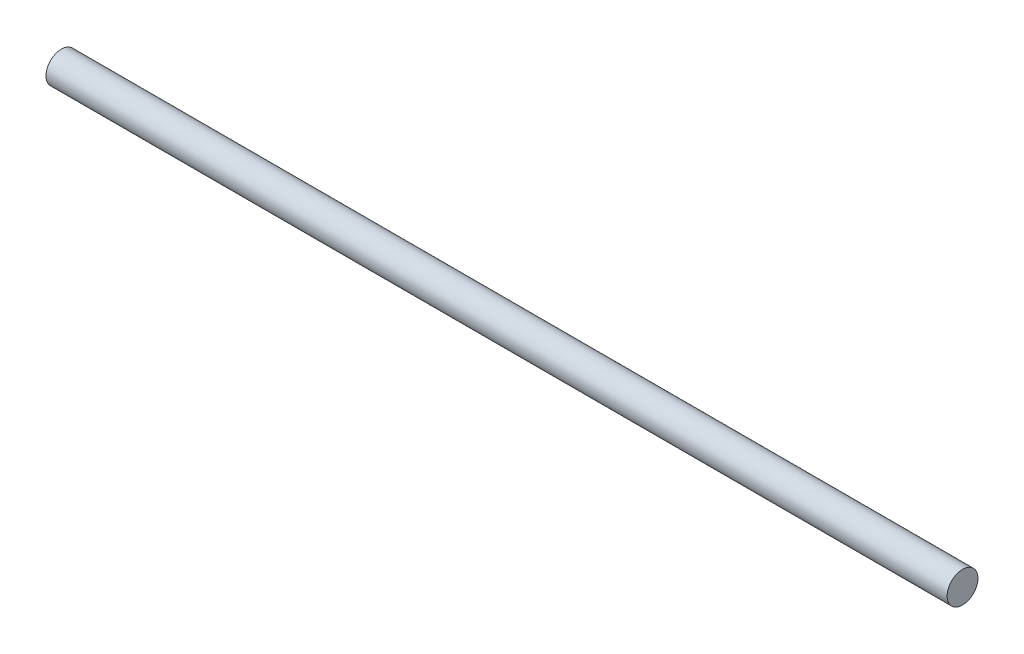
from build123d import *

# Parameters (mm, degrees)
SKETCH1_R           = 15
BOSS_EXTRUDE1_DEPTH = 875


with BuildPart() as part:
    # Sketch1 → Boss-Extrude1 (new body)
    with BuildSketch(Plane(origin=(0, 0, 0), x_dir=(0, 0, -1), z_dir=(1, 0, 0))):
        Circle(SKETCH1_R)
    extrude(amount=BOSS_EXTRUDE1_DEPTH)


solid = part.part
